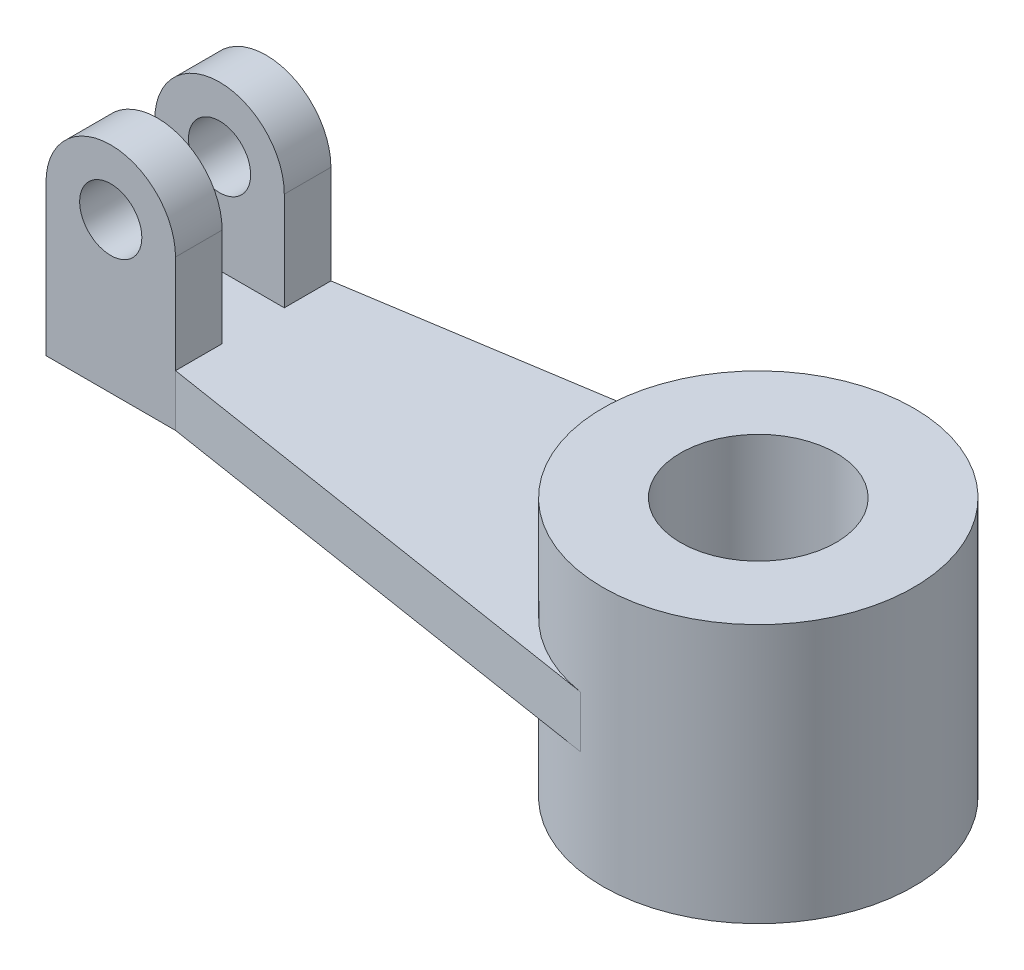
from build123d import *

# Parameters (mm, degrees)
SKETCH1_R           = 30
SKETCH1_R_2         = 15
BOSS_EXTRUDE6_DEPTH = 25
BOSS_EXTRUDE8_DEPTH = 5
SKETCH6_R           = 6
BOSS_EXTRUDE9_DEPTH = 9


with BuildPart() as part:
    # Sketch1 → Boss-Extrude6 (new body, symmetric)
    with BuildSketch(Plane(origin=(0, 0, 0), x_dir=(1, 0, 0), z_dir=(0, 1, 0))):
        with Locations(Location((0, 0, 0), (0, 0, 270))):  # turned: the seam where the file's is
            Circle(SKETCH1_R)
        with Locations(Location((0, 0, 0), (0, 0, 270))):  # turned: the seam where the file's is
            Circle(SKETCH1_R_2, mode=Mode.SUBTRACT)
    extrude(amount=BOSS_EXTRUDE6_DEPTH, both=True)

    # Sketch4 → Boss-Extrude8 (add, symmetric)
    with BuildSketch(Plane(origin=(0, 0, 0), x_dir=(1, 0, 0), z_dir=(0, 1, 0))):
        with BuildLine():
            Line((-122.5, 15), (-122.5, -15))
            Line((-122.5, -15), (-97.5, -15))
            Line((-97.5, -15), (-4.671688756, -29.634023084))
            ThreePointArc((-4.671688756, -29.634023084), (-30, 0), (-4.671688756, 29.634023084))
            Line((-4.671688756, 29.634023084), (-97.5, 15))
            Line((-97.5, 15), (-122.5, 15))
        make_face()
    extrude(amount=BOSS_EXTRUDE8_DEPTH, both=True)

    # Sketch6 → Boss-Extrude9 (add)
    with BuildSketch(Plane.XY.offset(15)):
        with BuildLine():
            Line((-97.5, 24), (-97.5, 5))
            Line((-97.5, 5), (-122.5, 5))
            Line((-122.5, 5), (-122.5, 24))
            ThreePointArc((-122.5, 24), (-110, 36.5), (-97.5, 24))
        make_face()
        with Locations((-110, 24)):
            Circle(SKETCH6_R, mode=Mode.SUBTRACT)
    boss_extrude9 = extrude(amount=-BOSS_EXTRUDE9_DEPTH)

    # Mirror1: Boss-Extrude9 across plane
    add(boss_extrude9.mirror(Plane.XY))


solid = part.part
